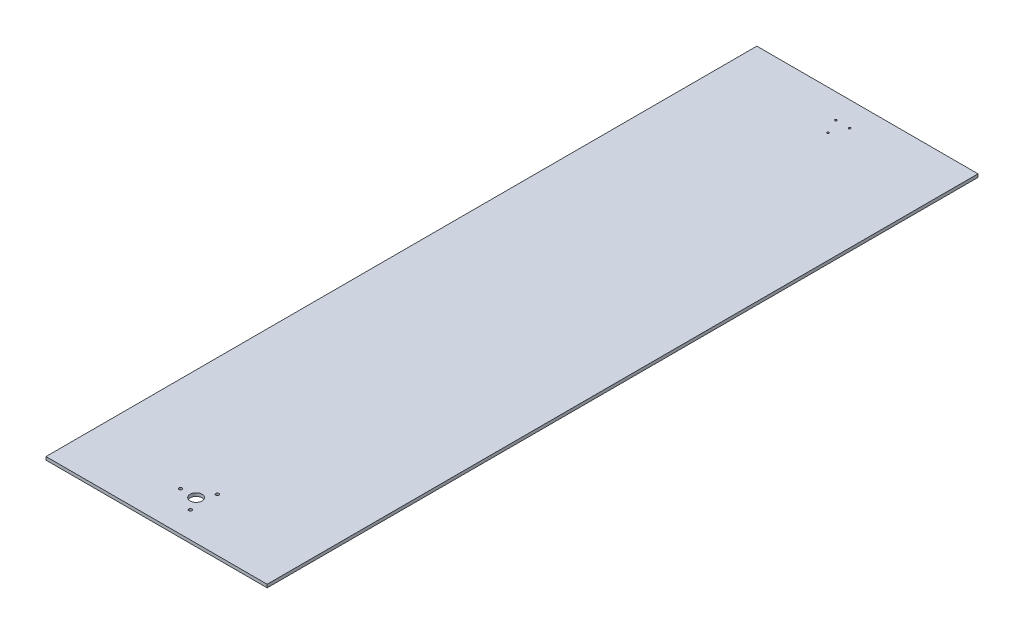
from build123d import *

# Parameters (mm, degrees)
SKETCH1_W           = 355.6
SKETCH1_H           = 127
SKETCH1_R           = 9.525
SKETCH1_R_2         = 2.5527
BOSS_EXTRUDE1_DEPTH = 5.08
SKETCH2_W           = 355.6
SKETCH2_H           = 1016
BOSS_EXTRUDE2_DEPTH = 5.08
SKETCH4_R           = 1.5875
CUT_EXTRUDE1_DEPTH  = 6.08


with BuildPart() as part:
    # Sketch1 → Boss-Extrude1 (new body)
    with BuildSketch(Plane(origin=(0, 0, 0), x_dir=(1, 0, 0), z_dir=(0, 1, 0))):
        Rectangle(SKETCH1_W, SKETCH1_H)
        Circle(SKETCH1_R, mode=Mode.SUBTRACT)
        with Locations((12.5, 21.650635095)):
            Circle(SKETCH1_R_2, mode=Mode.SUBTRACT)
        with Locations((12.5, -21.650635095)):
            Circle(SKETCH1_R_2, mode=Mode.SUBTRACT)
        with Locations((-25, 0)):
            Circle(SKETCH1_R_2, mode=Mode.SUBTRACT)
    extrude(amount=BOSS_EXTRUDE1_DEPTH)

    # Sketch2 → Boss-Extrude2 (add)
    with BuildSketch(Plane(origin=(0, 5.08, 0), x_dir=(1, 0, 0), z_dir=(0, 1, 0))):
        with Locations((0, 571.5)):
            Rectangle(SKETCH2_W, SKETCH2_H)
    extrude(amount=-BOSS_EXTRUDE2_DEPTH)

    # Sketch4 → Cut-Extrude1 (cut, through all)
    with BuildSketch(Plane(origin=(0, 5.08, 0), x_dir=(1, 0, 0), z_dir=(0, 1, 0))):
        with Locations((11.1125, 1039.8125)):
            Circle(SKETCH4_R)
        with Locations((-11.1125, 1039.8125)):
            Circle(SKETCH4_R)
        with Locations((0, 1016)):
            Circle(SKETCH4_R)
    extrude(amount=-CUT_EXTRUDE1_DEPTH, mode=Mode.SUBTRACT)


solid = part.part
